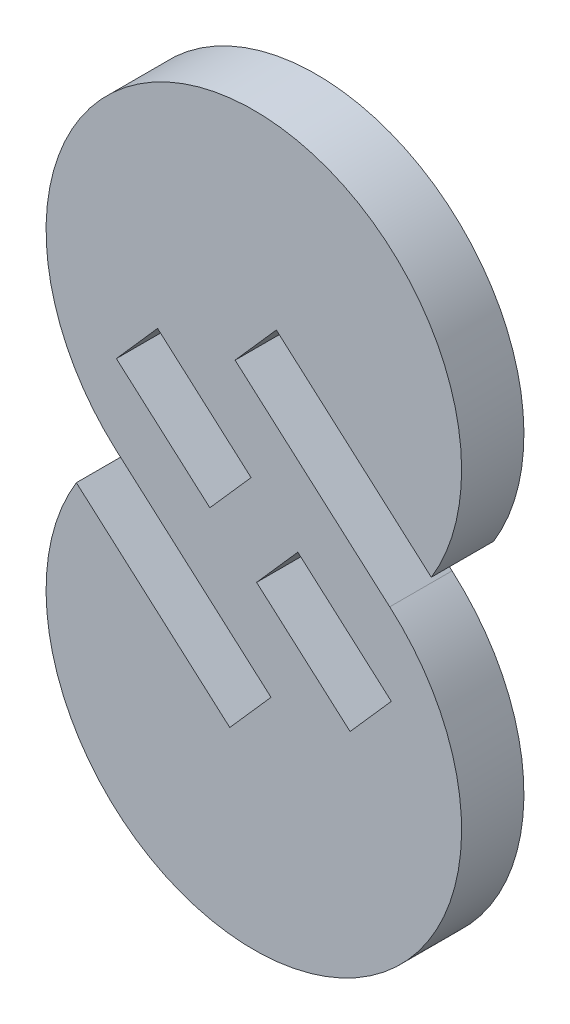
from build123d import *

# Parameters (mm, degrees)
SALIENTE_EXTRUIR1_DEPTH = 3
CORTAR_EXTRUIR2_REACH   = 5


with BuildPart() as part:
    # Croquis1 → Saliente-Extruir1 (new body)
    with BuildSketch(Plane.XY):
        with BuildLine():
            Line((-6.614427743, -7.499956375), (0.826760185, -14.062554531))
            Line((0.826760185, -14.062554531), (-1.157568138, -16.312541443))
            Line((-1.157568138, -16.312541443), (-8.541931773, -9.80005827))
            ThreePointArc((-8.541931773, -9.80005827), (1.549305596, -24.879455682), (6.540102602, -7.434879356))
            Line((6.540102602, -7.434879356), (-0.901085326, -0.872281201))
            Line((-0.901085326, -0.872281201), (1.083242997, 1.377705712))
            Line((1.083242997, 1.377705712), (8.541627127, -5.20005827))
            ThreePointArc((8.541627127, -5.20005827), (-1.500302366, 9.886814088), (-6.614427743, -7.499956375))
        make_face()
    extrude(amount=SALIENTE_EXTRUIR1_DEPTH)

    # Croquis2 → Cortar-Extruir2 (cut, up to next)
    with BuildSketch(Plane(origin=(0, 0, 0), x_dir=(-1, 0, 0), z_dir=(0, 0, -1)), mode=Mode.PRIVATE) as cortar_extruir2_sk1:
        Polygon((-4.63280312, -13.586006872), (-0.132829295, -9.617350226), (-2.117157618, -7.367363313), (-6.617131443, -11.336019959), align=None)
    cortar_extruir2_tool1 = extrude(cortar_extruir2_sk1.sketch, amount=-CORTAR_EXTRUIR2_REACH, mode=Mode.PRIVATE) & part.part
    add(cortar_extruir2_tool1.solids().sort_by_distance((3.37498, -10.476685, 0))[0], mode=Mode.SUBTRACT)
    # Croquis2 → Cortar-Extruir2 (cut, up to next)
    with BuildSketch(Plane(origin=(0, 0, 0), x_dir=(-1, 0, 0), z_dir=(0, 0, -1)), mode=Mode.PRIVATE) as cortar_extruir2_sk2:
        Polygon((6.617131443, -3.664365257), (4.63280312, -1.414378344), (0.132829295, -5.38303499), (2.117157618, -7.633021903), align=None)
    cortar_extruir2_tool2 = extrude(cortar_extruir2_sk2.sketch, amount=-CORTAR_EXTRUIR2_REACH, mode=Mode.PRIVATE) & part.part
    add(cortar_extruir2_tool2.solids().sort_by_distance((-3.37498, -4.5237, 0))[0], mode=Mode.SUBTRACT)


solid = part.part
